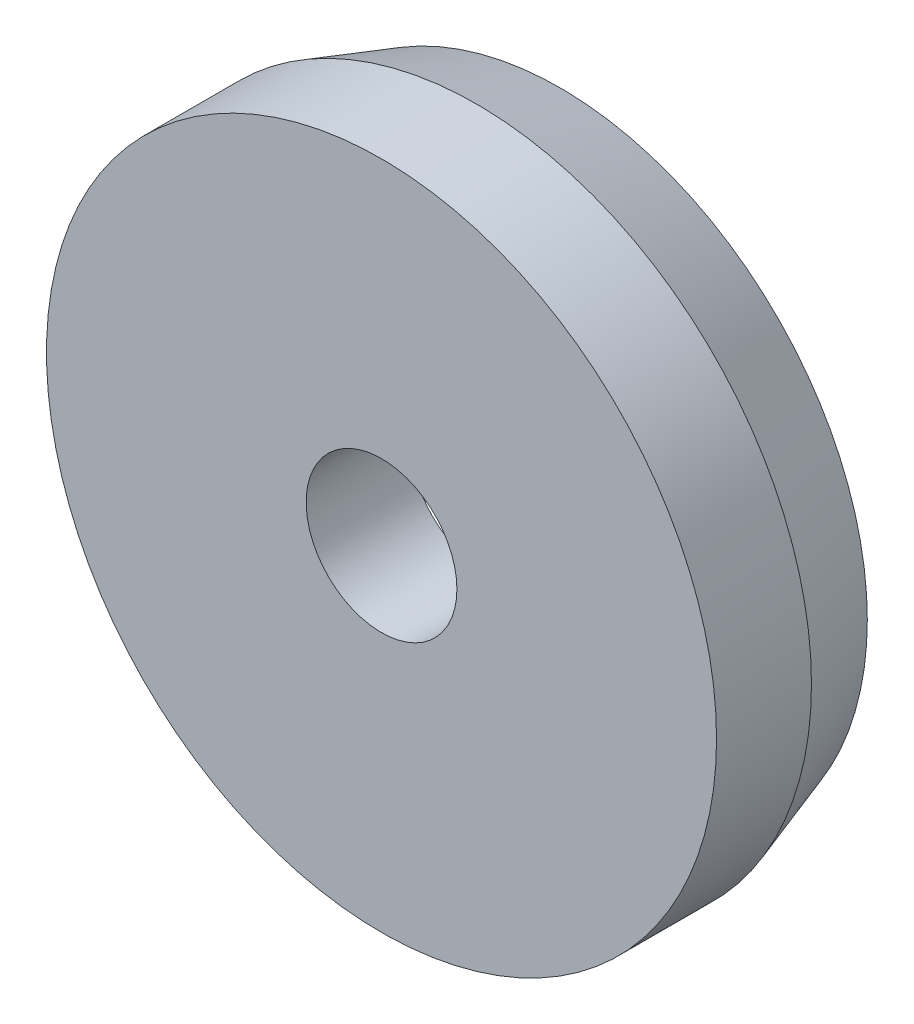
from build123d import *


with BuildPart() as part:
    # Sketch1 → Revolve1 (revolve)
    with BuildSketch(Plane(origin=(0, -10.25, 0), x_dir=(1, 0, 0), z_dir=(0, 1, 0))):
        with BuildLine():
            Line((0.6, 1.84), (0.55, 1.99))
            Line((0.55, 1.99), (0.38, 1.99))
            ThreePointArc((0.38, 1.99), (0.265994865, 1.907709235), (0.135, 1.856628064))
            Line((0.135, 1.856628064), (0.135, 1.67))
            Line((0.135, 1.67), (0.6, 1.67))
            Line((0.6, 1.67), (0.6, 1.84))
        make_face()
    revolve(axis=Axis((0, -10.25, -1.99), (0, 0, 1)))


solid = part.part
